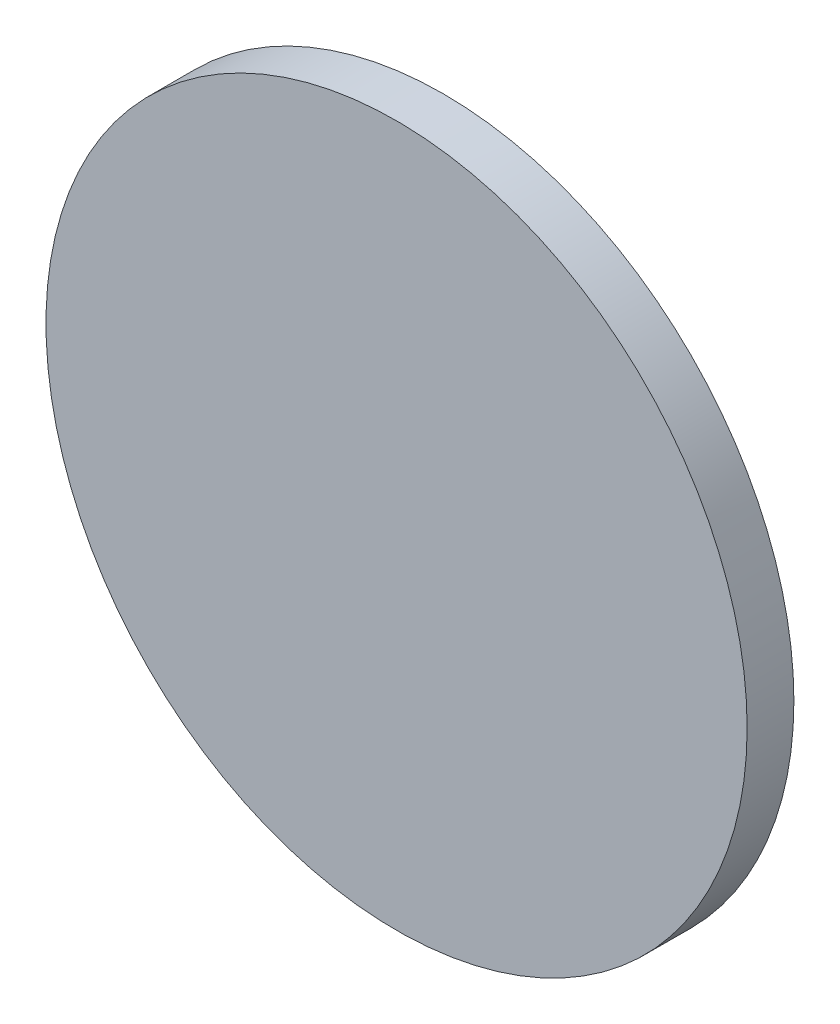
from build123d import *

# Parameters (mm, degrees)
SKETCH_1_W      = 60
SKETCH_1_H      = 60
EXTRUDE_1_DEPTH = 20


with BuildPart() as part:
    # 草图2 for 放样1 → 放样1 section 0
    with BuildSketch(Plane.XY.offset(50)):
        with BuildLine():
            # circular arc as an exact rational Bezier (weights 1, cos(half-angle), 1)
            Bezier((106.066017178, 106.066017178), (0, 212.132034356), (-106.066017178, 106.066017178), weights=[1, 0.707106781, 1])
            Bezier((-106.066017178, 106.066017178), (-212.132034356, 0), (-106.066017178, -106.066017178), weights=[1, 0.707106781, 1])
            Bezier((-106.066017178, -106.066017178), (0, -212.132034356), (106.066017178, -106.066017178), weights=[1, 0.707106781, 1])
            Bezier((106.066017178, -106.066017178), (212.132034356, 0), (106.066017178, 106.066017178), weights=[1, 0.707106781, 1])
        make_face()
    # 草图1 → 放样1 section 1
    with BuildSketch(Plane.XY):
        Rectangle(SKETCH_1_W, SKETCH_1_H)
    loft()

    # 草图3 → 凸台-拉伸1 (add)
    with BuildSketch(Plane.XY.offset(50)):
        with BuildLine():
            ThreePointArc((-106.066017178, -106.066017178), (0, -150), (106.066017178, -106.066017178))
            ThreePointArc((106.066017178, -106.066017178), (150, 0), (106.066017178, 106.066017178))
            ThreePointArc((106.066017178, 106.066017178), (0, 150), (-106.066017178, 106.066017178))
            ThreePointArc((-106.066017178, 106.066017178), (-150, 0), (-106.066017178, -106.066017178))
        make_face()
    extrude(amount=EXTRUDE_1_DEPTH)


solid = part.part
